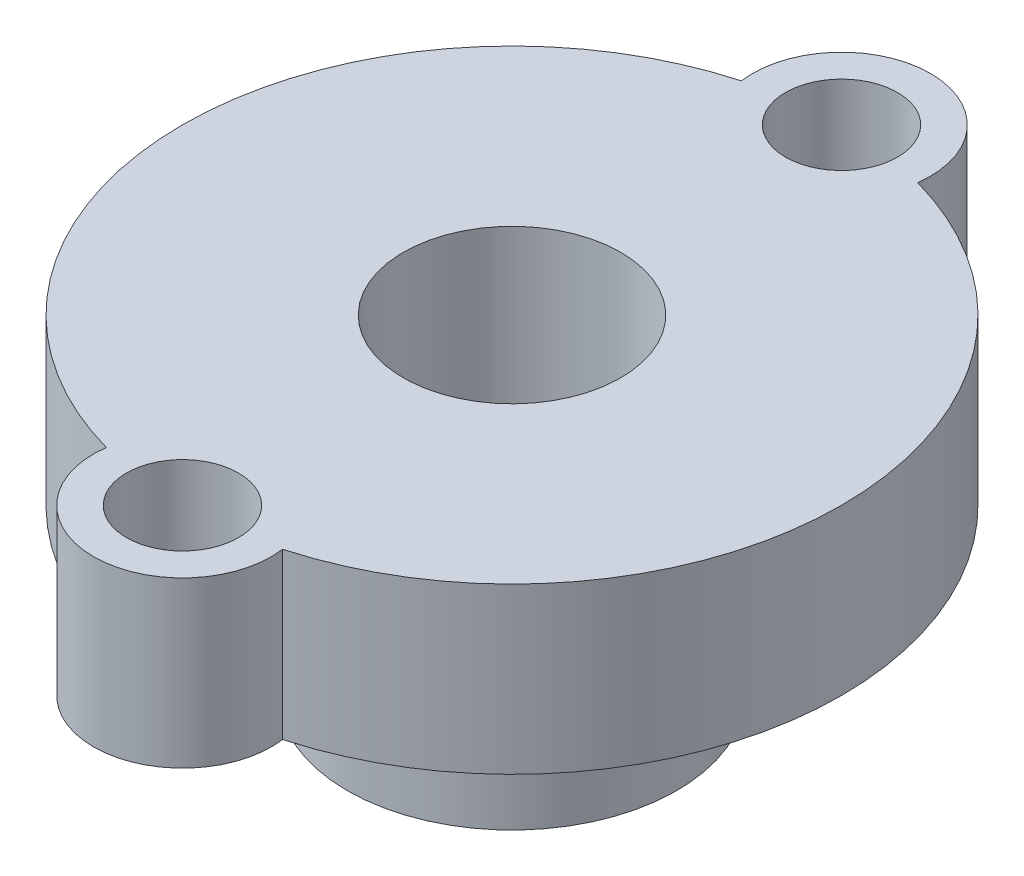
from build123d import *

# Parameters (mm, degrees)
CROQUIS1_R                   = 5
SALIENTE_EXTRUIR1_DEPTH      = 5
CROQUIS2_R                   = 1.7
SALIENTE_EXTRUIR2_DEPTH      = 5
TALADRO_DE_MARGEN_PARA_M61_D = 6.6


with BuildPart() as part:
    # Croquis1 → Saliente-Extruir1 (new body)
    with BuildSketch(Plane(origin=(0, 0, 0), x_dir=(1, 0, 0), z_dir=(0, 1, 0))):
        Circle(CROQUIS1_R)
    extrude(amount=SALIENTE_EXTRUIR1_DEPTH)

    # Croquis2 → Saliente-Extruir2 (add)
    with BuildSketch(Plane(origin=(0, 5, 0), x_dir=(1, 0, 0), z_dir=(0, 1, 0))):
        with BuildLine():
            ThreePointArc((-2.675283116, 9.6355), (-10, 0), (-2.675283116, -9.6355))
            ThreePointArc((-2.675283116, -9.6355), (0, -12.7), (2.675283116, -9.6355))
            ThreePointArc((2.675283116, -9.6355), (10, 0), (2.675283116, 9.6355))
            ThreePointArc((2.675283116, 9.6355), (0, 12.7), (-2.675283116, 9.6355))
        make_face()
        with Locations((0, 10)):
            Circle(CROQUIS2_R, mode=Mode.SUBTRACT)
        with Locations((0, -10)):
            Circle(CROQUIS2_R, mode=Mode.SUBTRACT)
    extrude(amount=SALIENTE_EXTRUIR2_DEPTH)

    # Taladro de margen para M61 (through all)
    with Locations(Plane(origin=(0, 0, 0), x_dir=(-1, 0, 0), z_dir=(0, -1, 0))):
        with Locations((0, 0)):
            Hole(TALADRO_DE_MARGEN_PARA_M61_D / 2)


solid = part.part
